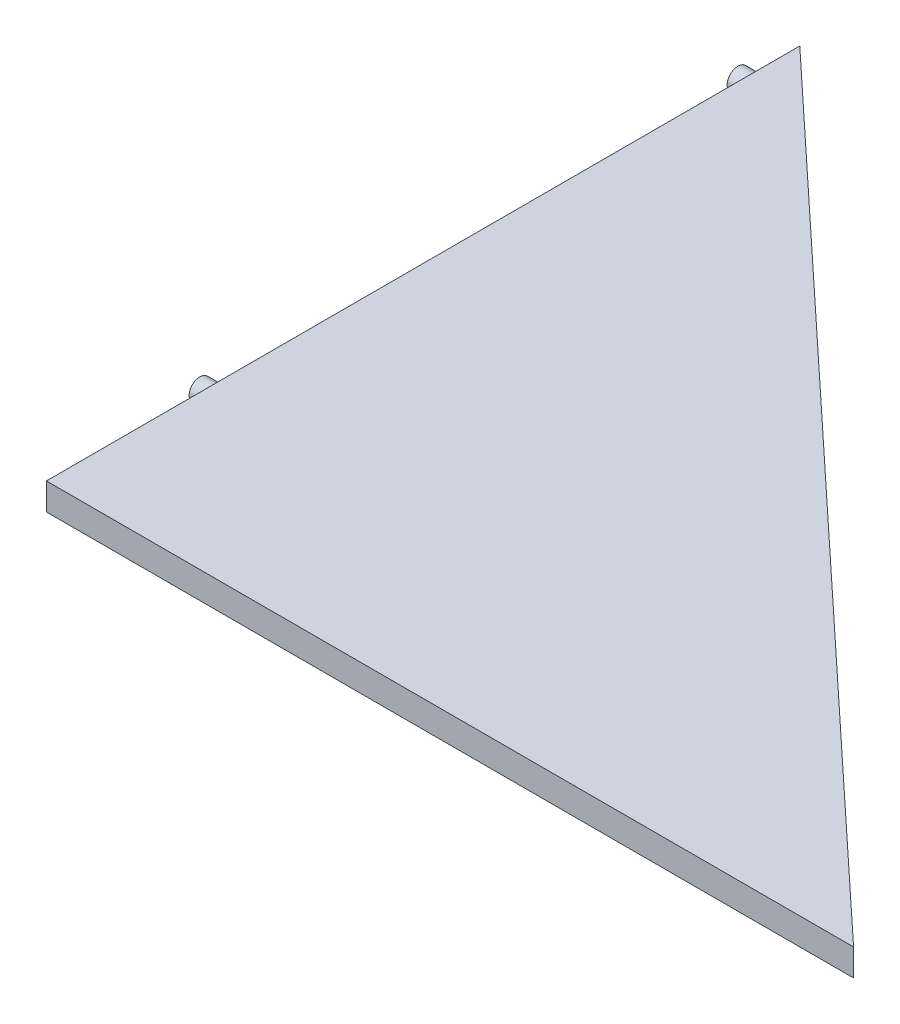
from build123d import *

# Parameters (mm, degrees)
BOSS_EXTRUDE1_DEPTH = 5
SKETCH2_R           = 2
BOSS_EXTRUDE2_DEPTH = 3


with BuildPart() as part:
    # Sketch1 → Boss-Extrude1 (new body)
    with BuildSketch(Plane(origin=(0, 0, 0), x_dir=(1, 0, 0), z_dir=(0, 1, 0))):
        Polygon((-50.263774427, 46.912856132), (99.736225573, -93.087143868), (-50.263774427, -93.087143868), align=None)
    extrude(amount=BOSS_EXTRUDE1_DEPTH)

    # Sketch2 → Boss-Extrude2 (add)
    with BuildSketch(Plane.ZY.offset(50.263774427)):
        with Locations((-38.421386897, 2.5)):
            Circle(SKETCH2_R)
        with Locations((61.578613103, 2.5)):
            Circle(SKETCH2_R)
    extrude(amount=BOSS_EXTRUDE2_DEPTH)


solid = part.part
